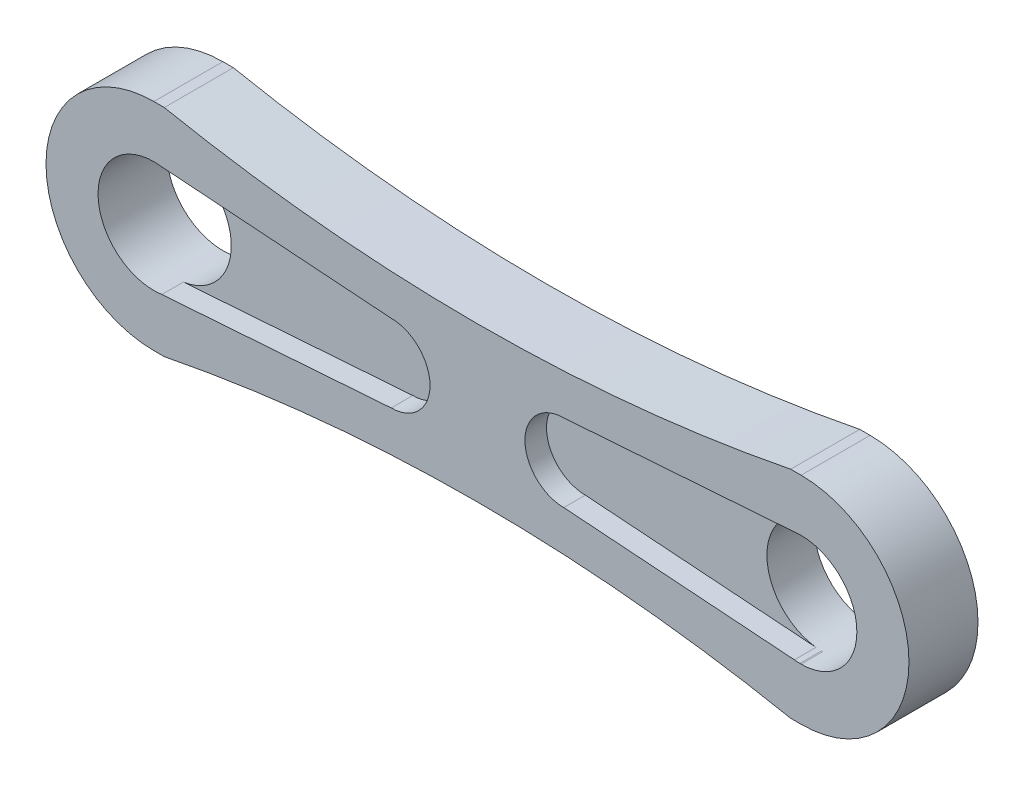
from build123d import *

# Parameters (mm, degrees)
SKETCH1_R           = 3.286877418
SKETCH1_R_2         = 3.282339501
BOSS_EXTRUDE2_DEPTH = 4.064
CUT_EXTRUDE1_DEPTH  = 1.27
CUT_EXTRUDE2_DEPTH  = 5.064


with BuildPart() as part:
    # Sketch1 → Boss-Extrude2 (new body)
    with BuildSketch(Plane.XY):
        with BuildLine():
            Line((-19.05, 6.35), (19.05, 6.35))
            ThreePointArc((19.05, 6.35), (25.4, 0), (19.05, -6.35))
            Line((19.05, -6.35), (-19.05, -6.35))
            ThreePointArc((-19.05, -6.35), (-25.4, 0), (-19.05, 6.35))
        make_face()
        with Locations((-19.05, 0)):
            Circle(SKETCH1_R, mode=Mode.SUBTRACT)
        with Locations((19.05, 0)):
            Circle(SKETCH1_R_2, mode=Mode.SUBTRACT)
    extrude(amount=BOSS_EXTRUDE2_DEPTH)

    # Sketch2 → Cut-Extrude1 (cut)
    with BuildSketch(Plane.XY.offset(4.064)):
        with BuildLine():
            Line((-19.05, 3.286877418), (-5.08, 2.286))
            ThreePointArc((-5.08, 2.286), (-2.794, 0), (-5.08, -2.286))
            Line((-5.08, -2.286), (-19.05, -3.286877418))
            Line((-19.05, -3.286877418), (-19.05, 3.286877418))
        make_face()
        with BuildLine():
            Line((19.05, -3.286877418), (5.08, -2.286))
            ThreePointArc((5.08, -2.286), (2.794, 0), (5.08, 2.286))
            Line((5.08, 2.286), (19.05, 3.286877418))
            Line((19.05, 3.286877418), (19.05, -3.286877418))
        make_face()
    extrude(amount=-CUT_EXTRUDE1_DEPTH, mode=Mode.SUBTRACT)

    # Sketch4 → Cut-Extrude2 (cut, through all)
    with BuildSketch(Plane.XY.offset(4.064)):
        with BuildLine():
            ThreePointArc((18.437330889, 6.35), (73.326339368, 39.20432916), (94.889393238, 99.430942082))
            ThreePointArc((94.889393238, 99.430942082), (-60.226612922, 172.75728145), (-18.437330889, 6.35))
            Line((-18.437330889, 6.35), (18.437330889, 6.35))
        make_face()
        with BuildLine():
            Line((18.437330889, 6.35), (-18.437330889, 6.35))
            ThreePointArc((-18.437330889, 6.35), (-18.146321247, 6.29282972), (-17.855134345, 6.236569254))
            ThreePointArc((-17.855134345, 6.236569254), (-1.97e-07, 4.541548843), (17.855133958, 6.23656918))
            ThreePointArc((17.855133958, 6.23656918), (18.146321054, 6.292829682), (18.437330889, 6.35))
        make_face()
        with BuildLine():
            ThreePointArc((18.437330889, -6.35), (18.146321056, -6.292829683), (17.855133961, -6.236569181))
            ThreePointArc((17.855133961, -6.236569181), (-1.46e-07, -4.541548843), (-17.855134248, -6.236569236))
            ThreePointArc((-17.855134248, -6.236569236), (-18.146321199, -6.292829711), (-18.437330889, -6.35))
            Line((-18.437330889, -6.35), (18.437330889, -6.35))
        make_face()
        with BuildLine():
            Line((18.437330889, -6.35), (-18.437330889, -6.35))
            ThreePointArc((-18.437330889, -6.35), (-60.226612922, -172.75728145), (94.889393238, -99.430942082))
            ThreePointArc((94.889393238, -99.430942082), (73.326339368, -39.20432916), (18.437330889, -6.35))
        make_face()
    extrude(amount=-CUT_EXTRUDE2_DEPTH, mode=Mode.SUBTRACT)


solid = part.part
